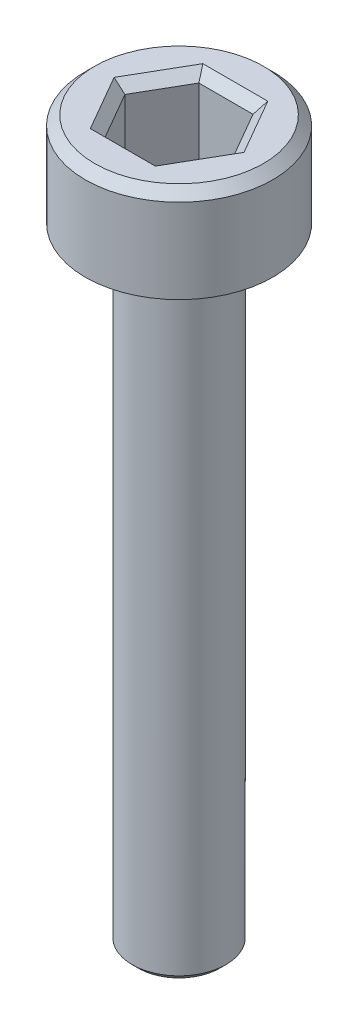
from build123d import *

# Parameters (mm, degrees)
SKETCH1_R           = 3
BOSS_EXTRUDE1_DEPTH = 3
CHAMFER1_SIZE       = 0.3
CUT_EXTRUDE1_DEPTH  = 2.5
CHAMFER2_SIZE       = 0.3
SKETCH3_R           = 1.5
BOSS_EXTRUDE2_DEPTH = 20
CHAMFER3_SIZE       = 0.2


with BuildPart() as part:
    # Sketch1 → Boss-Extrude1 (new body)
    with BuildSketch(Plane(origin=(0, 0, 0), x_dir=(1, 0, 0), z_dir=(0, 1, 0))):
        with Locations(Location((0, 0, 0), (0, 0, 270))):  # turned: the seam where the file's is
            Circle(SKETCH1_R)
    extrude(amount=BOSS_EXTRUDE1_DEPTH)

    # Chamfer1
    chamfer1_edges = [part.edges().sort_by_distance(p)[0] for p in [
        (0, 3, -3),
    ]]
    chamfer(chamfer1_edges, length=CHAMFER1_SIZE)

    # Sketch2 → Cut-Extrude1 (cut)
    with BuildSketch(Plane(origin=(0, 3, 0), x_dir=(1, 0, 0), z_dir=(0, 1, 0))):
        Polygon((1.732050808, 0), (0.866025404, 1.5), (-0.866025404, 1.5), (-1.732050808, 0), (-0.866025404, -1.5), (0.866025404, -1.5), align=None)
    extrude(amount=-CUT_EXTRUDE1_DEPTH, mode=Mode.SUBTRACT)

    # Chamfer2
    chamfer2_edges = [part.edges().sort_by_distance(p)[0] for p in [
        (1.299038106, 3, 0.75),
        (1.299038106, 3, -0.75),
        (0, 3, -1.5),
        (-1.299038106, 3, -0.75),
        (-1.299038106, 3, 0.75),
        (0, 3, 1.5),
    ]]
    chamfer(chamfer2_edges, length=CHAMFER2_SIZE)

    # Sketch3 → Boss-Extrude2 (add)
    with BuildSketch(Plane.XZ):
        with Locations(Location((0, 0, 0), (0, 0, 90))):  # turned: the seam where the file's is
            Circle(SKETCH3_R)
    extrude(amount=BOSS_EXTRUDE2_DEPTH)

    # Chamfer3
    chamfer3_edges = [part.edges().sort_by_distance(p)[0] for p in [
        (0, -20, -1.5),
    ]]
    chamfer(chamfer3_edges, length=CHAMFER3_SIZE)


solid = part.part
